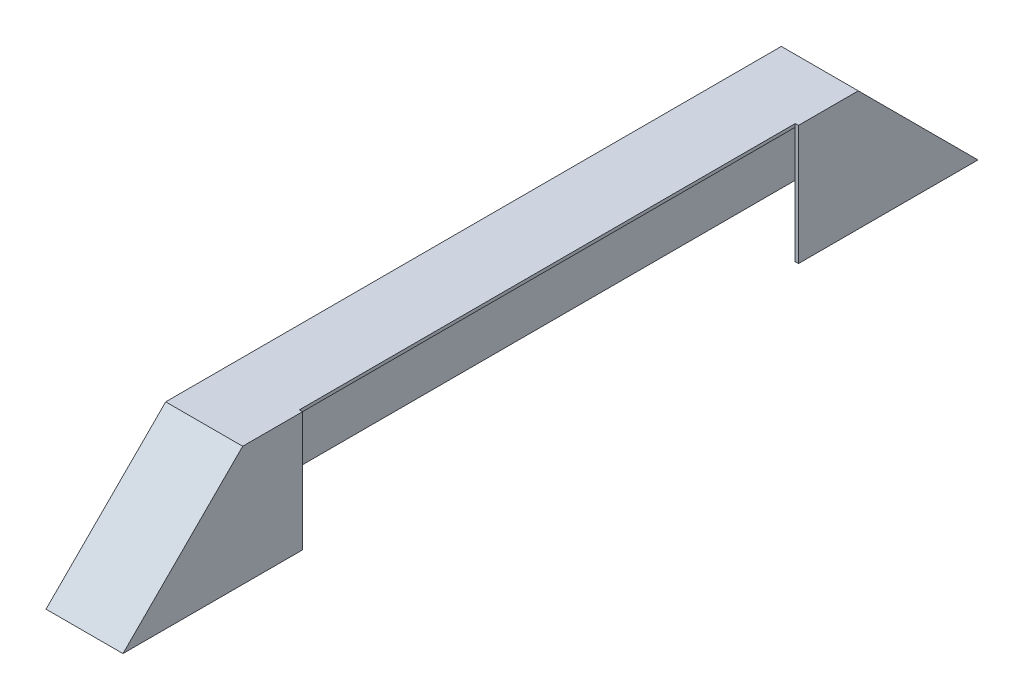
from build123d import *

# Parameters (mm, degrees)
BOSS_EXTRUDE1_DEPTH = 114.3
SHELL3_T            = -4.7625
SKETCH8_W           = 736.6
SKETCH8_H           = 177.8
CUT_EXTRUDE2_DEPTH  = 4.7625


with BuildPart() as part:
    # Sketch1 → Boss-Extrude1 (new body)
    with BuildSketch(Plane(origin=(0, 0, 0), x_dir=(0, 0, -1), z_dir=(1, 0, 0))):
        Polygon((-457.2, 88.9), (-635, -88.9), (-457.2, -88.9), (457.2, -88.9), (635, -88.9), (457.2, 88.9), align=None)
    extrude(amount=BOSS_EXTRUDE1_DEPTH)

    # Shell3
    shell3_openings = [part.faces().sort_by_distance(p)[0] for p in [
        (57.15, -88.9, 0),
    ]]
    offset(amount=SHELL3_T, openings=shell3_openings, kind=Kind.INTERSECTION)

    # Sketch8 → Cut-Extrude2 (cut)
    with BuildSketch(Plane(origin=(114.3, 0, 0), x_dir=(0, 0, -1), z_dir=(1, 0, 0))):
        Rectangle(SKETCH8_W, SKETCH8_H)
    extrude(amount=-CUT_EXTRUDE2_DEPTH, mode=Mode.SUBTRACT)


solid = part.part
